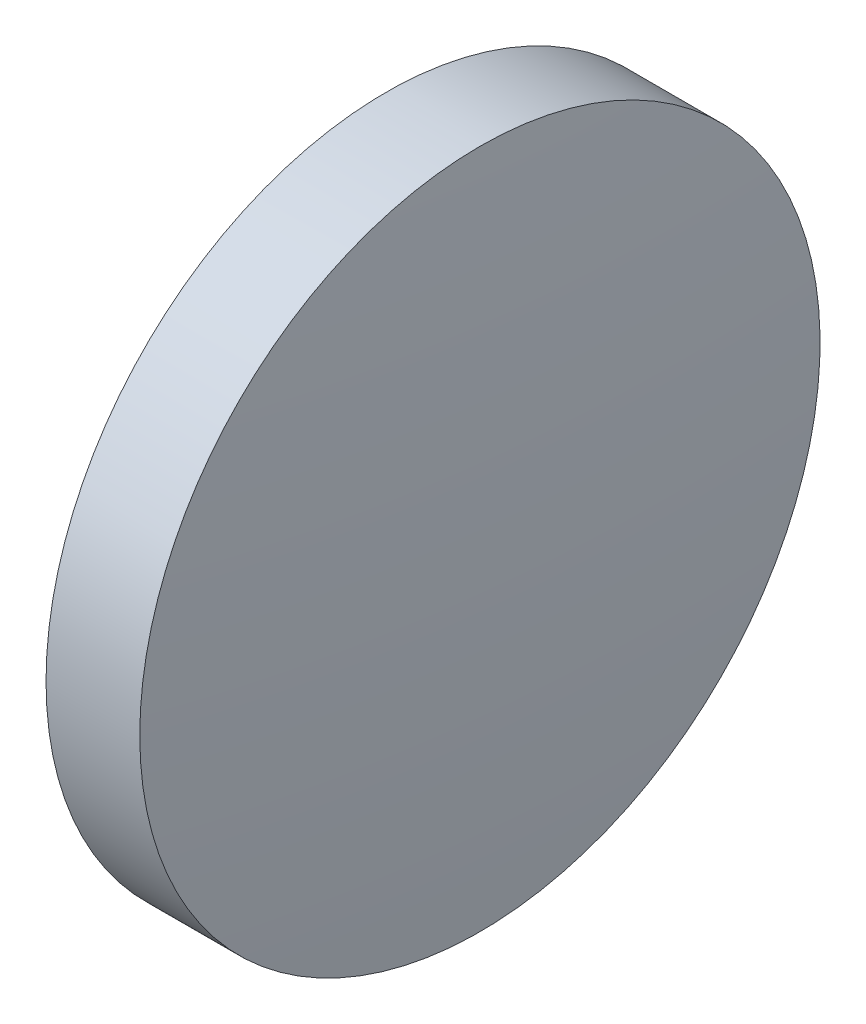
from build123d import *


with BuildPart() as part:
    # 草图1 → 旋转1 (revolve)
    with BuildSketch(Plane.XY):
        with BuildLine():
            Line((115.764555476, 65.233554926), (115.764555476, 77.933554926))
            Line((115.764555476, 77.933554926), (119.264555476, 77.933554926))
            ThreePointArc((119.264555476, 77.933554926), (119.639507076, 71.588474281), (119.764555476, 65.233554926))
            Line((119.764555476, 65.233554926), (115.764555476, 65.233554926))
        make_face()
    revolve(axis=Axis((110.165373228, 65.233554926, 0), (1, 0, 0)))


solid = part.part
